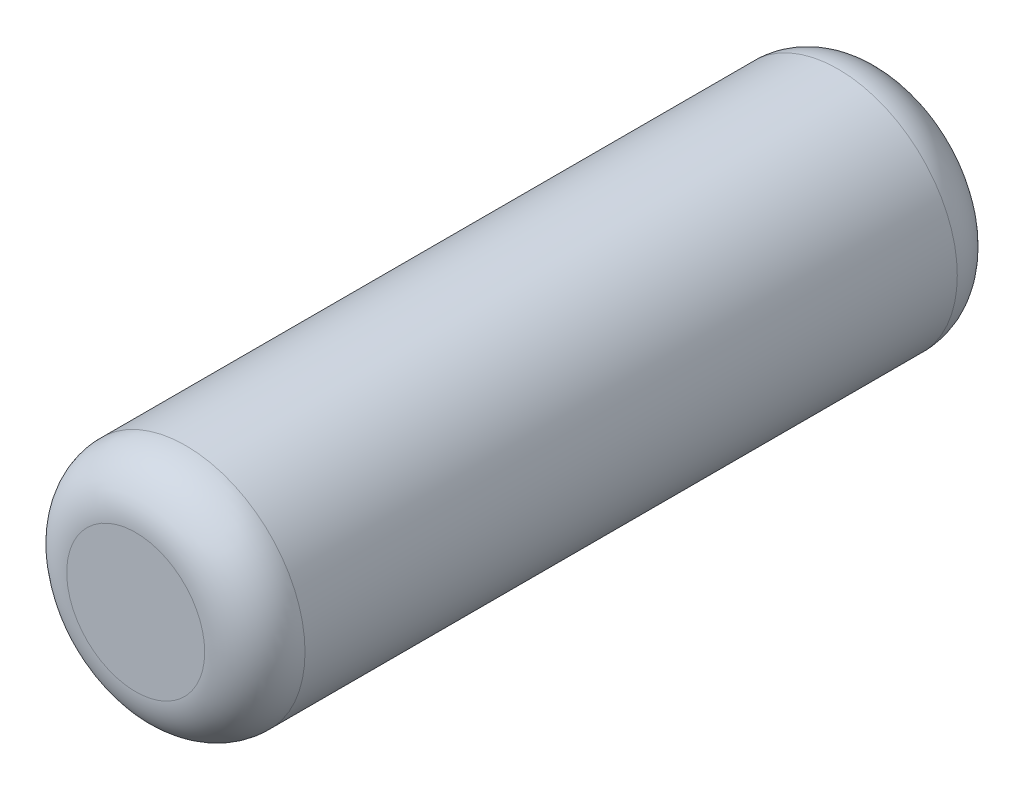
from build123d import *

# Parameters (mm, degrees)
SKETCH1_R           = 120.65
BOSS_EXTRUDE1_DEPTH = 762
FILLET2_R           = 50.8
CUT_EXTRUDE1_START  = -25.4
SKETCH2_R           = 101.6
CUT_EXTRUDE1_DEPTH  = 711.2


with BuildPart() as part:
    # Sketch1 → Boss-Extrude1 (new body)
    with BuildSketch(Plane.XY):
        Circle(SKETCH1_R)
    extrude(amount=BOSS_EXTRUDE1_DEPTH)

    # Fillet2
    fillet2_edges = [part.edges().sort_by_distance(p)[0] for p in [
        (-120.65, 0, 0),
        (-120.65, 0, 762),
    ]]
    fillet(fillet2_edges, radius=FILLET2_R)

    # Sketch2 → Cut-Extrude1 (cut)
    with BuildSketch(Plane.XY.offset(762).offset(CUT_EXTRUDE1_START)):
        Circle(SKETCH2_R)
    extrude(amount=-CUT_EXTRUDE1_DEPTH, mode=Mode.SUBTRACT)


solid = part.part
